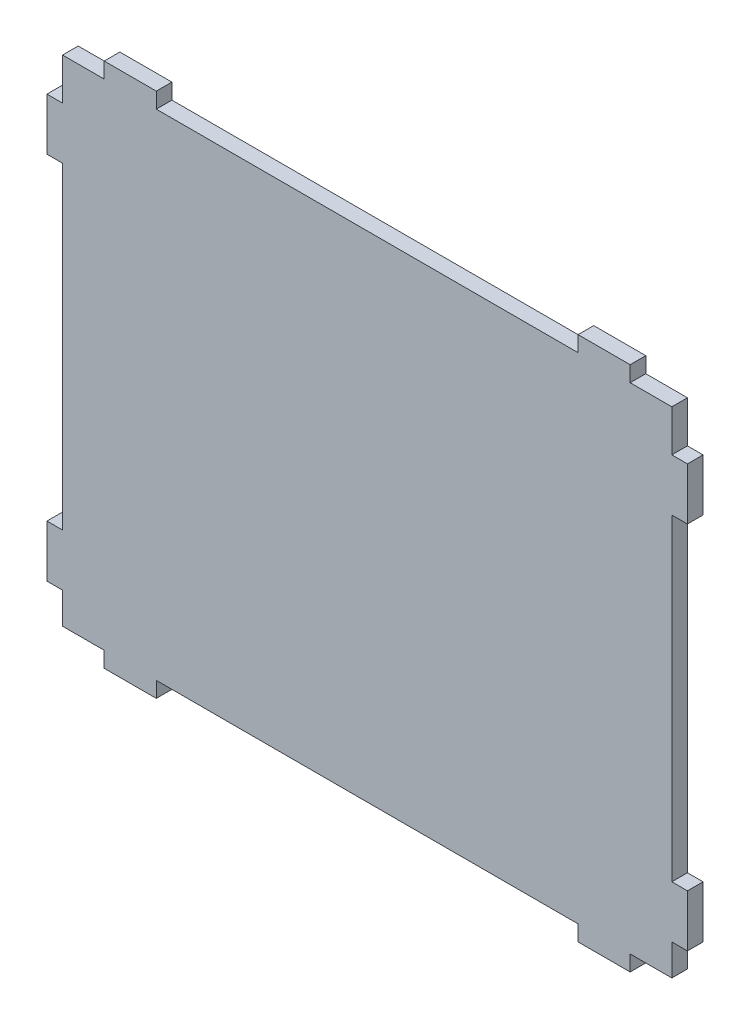
from build123d import *

# Parameters (mm, degrees)
SALIENTE_EXTRUIR1_DEPTH = 3


with BuildPart() as part:
    # Croquis1 → Saliente-Extruir1 (new body)
    with BuildSketch(Plane.XY):
        Polygon((-50.830323555, 36.278811864), (-42.830323555, 36.278811864), (-42.830323555, 39.278811864), (-32.830323555, 39.278811864), (-32.830323555, 36.278811864), (48.169676445, 36.278811864), (48.169676445, 39.278811864), (58.169676445, 39.278811864), (58.169676445, 36.278811864), (66.169676445, 36.278811864), (66.169676445, 28.278811864), (69.169676445, 28.278811864), (69.169676445, 18.278811864), (66.169676445, 18.278811864), (66.169676445, -42.721188136), (69.169676445, -42.721188136), (69.169676445, -52.721188136), (66.169676445, -52.721188136), (66.169676445, -58.721188136), (58.169676445, -58.721188136), (58.169676445, -61.721188136), (48.169676445, -61.721188136), (48.169676445, -58.721188136), (-32.830323555, -58.721188136), (-32.830323555, -61.721188136), (-42.830323555, -61.721188136), (-42.830323555, -58.721188136), (-50.830323555, -58.721188136), (-50.830323555, -52.721188136), (-53.830323555, -52.721188136), (-53.830323555, -42.721188136), (-50.830323555, -42.721188136), (-50.830323555, 18.278811864), (-53.830323555, 18.278811864), (-53.830323555, 28.278811864), (-50.830323555, 28.278811864), align=None)
    extrude(amount=SALIENTE_EXTRUIR1_DEPTH)


solid = part.part
